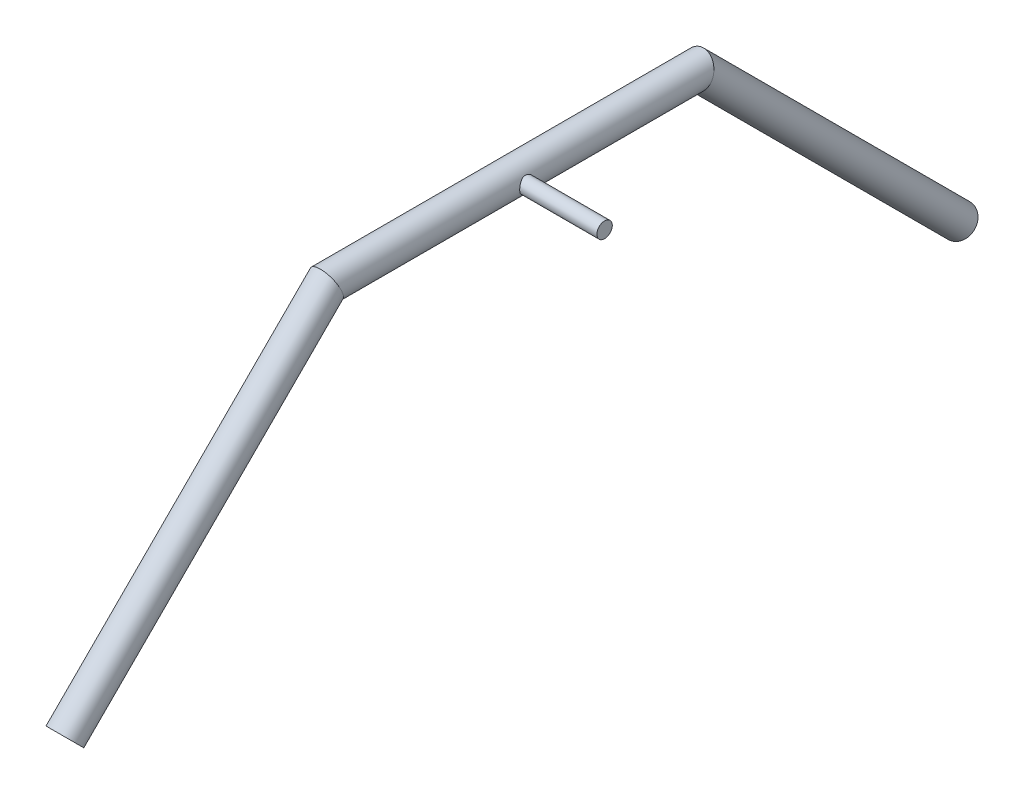
from build123d import *

# Parameters (mm, degrees)
SWEEP1_PROFILE_R     = 12.7
CUT_SWEEP1_PROFILE_R = 9.525
SKETCH19_R           = 6.35
BOSS_EXTRUDE1_DEPTH  = 76.2


with BuildPart() as part:
    # Sweep1: sweep along a path in Sketch2
    with BuildLine(Plane(origin=(0, 0, 0), x_dir=(0, 0, -1), z_dir=(1, 0, 0))) as sweep1_path:
        Line((-248.182278836, -217.015933946), (-32.65613193, -1.489787041))
        Line((-32.65613193, -1.489787041), (272.14386807, -1.489787041))
        Line((272.14386807, -1.489787041), (487.670014975, -217.015933946))
    # Sweep1 profile (on start of the path) → Sweep1 (sweep)
    with BuildSketch(Plane(origin=(0, -217.015933946, 248.182278836), x_dir=(0, 0.7071067811865461, 0.707106781186549), z_dir=(0, 0.707106781186549, -0.7071067811865461))):
        Circle(SWEEP1_PROFILE_R)
    sweep(path=sweep1_path.line, transition=Transition.RIGHT)

    # Cut-Sweep1: sweep along a path in Sketch2_2
    with BuildLine(Plane(origin=(0, 0, 0), x_dir=(0, 0, -1), z_dir=(1, 0, 0))) as cut_sweep1_path:
        Line((-248.182278836, -217.015933946), (-32.65613193, -1.489787041))
        Line((-32.65613193, -1.489787041), (272.14386807, -1.489787041))
        Line((272.14386807, -1.489787041), (487.670014975, -217.015933946))
    # Cut-Sweep1 profile (on start of the path) → Cut-Sweep1 (sweep, cut)
    with BuildSketch(Plane(origin=(0, -217.015933946, 248.182278836), x_dir=(0, 0.7071067811865461, 0.707106781186549), z_dir=(0, 0.707106781186549, -0.7071067811865461))):
        Circle(CUT_SWEEP1_PROFILE_R)
    sweep(path=cut_sweep1_path.line, transition=Transition.RIGHT, mode=Mode.SUBTRACT)

    # Sketch19 → Boss-Extrude1 (add)
    with BuildSketch(Plane(origin=(0, 0, 0), x_dir=(0, 0, -1), z_dir=(1, 0, 0))):
        with Locations((119.74386807, -1.489787041)):
            Circle(SKETCH19_R)
    extrude(amount=BOSS_EXTRUDE1_DEPTH)


solid = part.part
